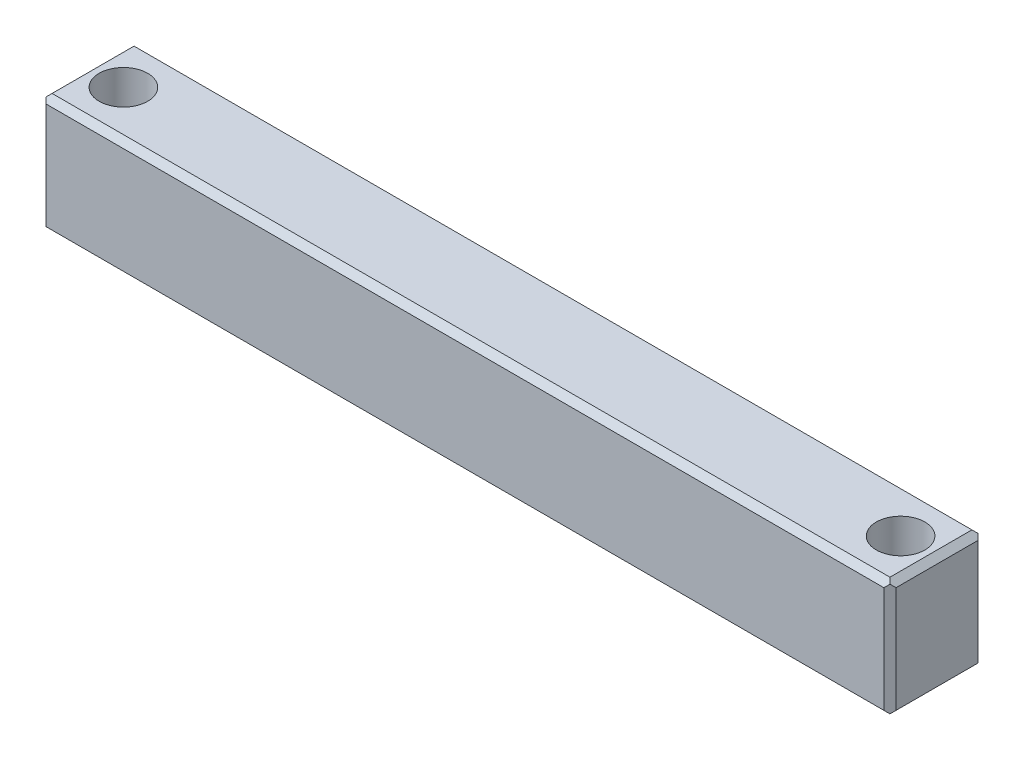
from build123d import *

# Parameters (mm, degrees)
SKETCH1_W           = 7.75
SKETCH1_H           = 9.75
BOSS_EXTRUDE1_DEPTH = 70
SKETCH4_R           = 2
CUT_EXTRUDE3_DEPTH  = 9.75
CHAMFER1_SIZE       = 0.5
CHAMFER2_SIZE       = 0.5


with BuildPart() as part:
    # Sketch1 → Boss-Extrude1 (new body)
    with BuildSketch(Plane(origin=(0, 0, 0), x_dir=(0, 0, -1), z_dir=(1, 0, 0))):
        with Locations((3.875, 4.875)):
            Rectangle(SKETCH1_W, SKETCH1_H)
    extrude(amount=BOSS_EXTRUDE1_DEPTH)

    # Sketch4 → Cut-Extrude3 (cut)
    with BuildSketch(Plane(origin=(0, 9.75, 0), x_dir=(1, 0, 0), z_dir=(0, 1, 0))):
        with Locations((3, 3.875)):
            Circle(SKETCH4_R)
        with Locations((67, 3.875)):
            Circle(SKETCH4_R)
    extrude(amount=-CUT_EXTRUDE3_DEPTH, mode=Mode.SUBTRACT)

    # Chamfer1
    chamfer1_edges = [part.edges().sort_by_distance(p)[0] for p in [
        (70, 4.875, -7.75),
        (70, 9.75, -3.875),
        (70, 4.875, 0),
        (0, 9.75, -3.875),
        (0, 4.875, -7.75),
        (0, 0, -3.875),
        (0, 4.875, 0),
        (70, 0, -3.875),
    ]]
    chamfer(chamfer1_edges, length=CHAMFER1_SIZE)

    # Chamfer2
    chamfer2_edges = [part.edges().sort_by_distance(p)[0] for p in [
        (35, 0, -7.75),
        (35, 0, 0),
        (35, 9.75, -7.75),
        (35, 9.75, 0),
    ]]
    chamfer(chamfer2_edges, length=CHAMFER2_SIZE)


solid = part.part
